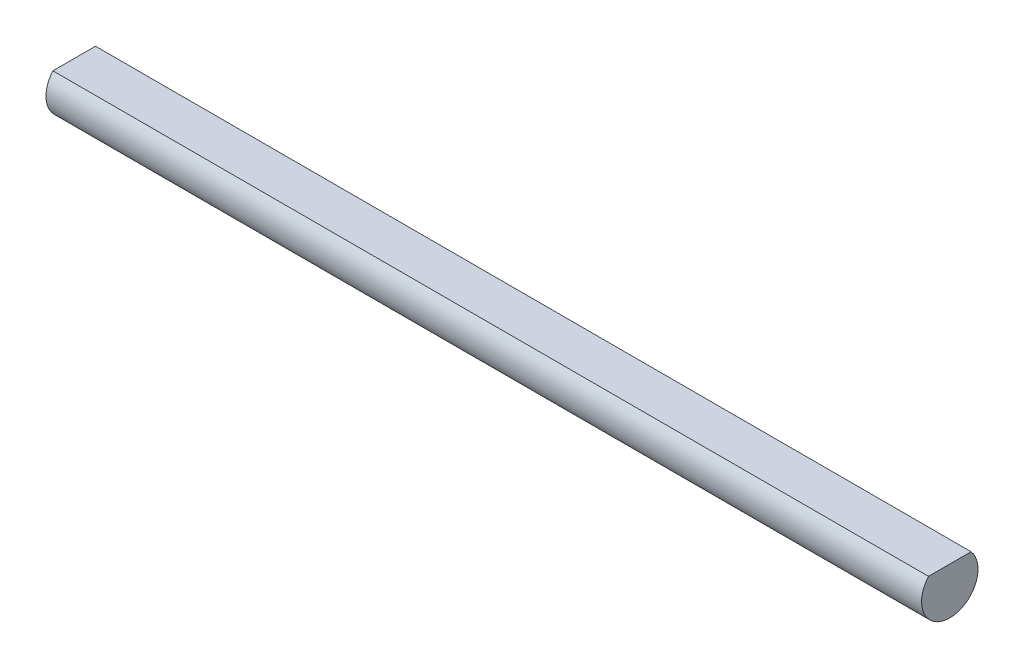
from build123d import *

# Parameters (mm, degrees)
BOSS_EXTRUDE1_DEPTH      = 22.5
BOSS_EXTRUDE1_DEPTH_BACK = 22.5


with BuildPart() as part:
    # Sketch1 → Boss-Extrude1 (new, two sides: drawn at the far end of the back side and taken through both)
    with BuildSketch(Plane(origin=(0, 0, 0), x_dir=(0, 0, -1), z_dir=(1, 0, 0)).offset(-BOSS_EXTRUDE1_DEPTH_BACK)):
        with BuildLine():
            ThreePointArc((-1.095445115, 0.95), (0, -1.45), (1.095445115, 0.95))
            Line((1.095445115, 0.95), (-1.095445115, 0.95))
        make_face()
    extrude(amount=BOSS_EXTRUDE1_DEPTH + BOSS_EXTRUDE1_DEPTH_BACK)


solid = part.part
